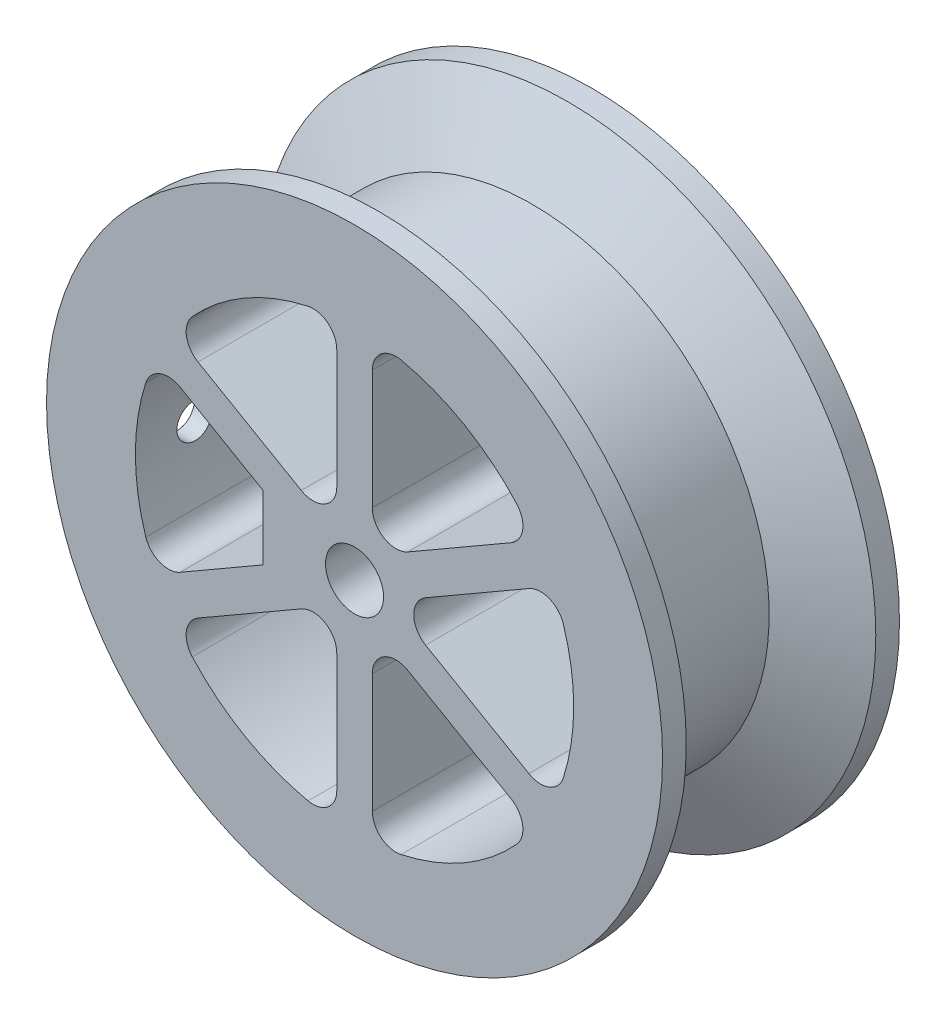
from build123d import *

# Parameters (mm, degrees)
SKETCH4_R                 = 3.1115
CUT_EXTRUDE1_DEPTH        = 26.4
CUT_EXTRUDE2_DEPTH        = 26.4
CIRPATTERN1_COUNT         = 6
SKETCH6_W                 = 5.08
SKETCH6_H                 = 6.929069256
BOSS_EXTRUDE2_DEPTH       = 25.4
F_4_CLEARANCE_HOLE1_D     = 3.4544
F_4_CLEARANCE_HOLE1_DEPTH = 12.7
F_4_CLEARANCE_HOLE1_TIP   = 1.037806461
SKETCH10_R                = 1.905
CUT_EXTRUDE3_DEPTH        = 24.20925
CUT_EXTRUDE7_START        = -1.778
CUT_EXTRUDE7_DEPTH        = 2.413


with BuildPart() as part:
    # Sketch2 → Revolve1 (revolve)
    with BuildSketch(Plane(origin=(0, 0, 0), x_dir=(1, 0, 0), z_dir=(0, 1, 0))):
        Polygon((0, 12.7), (33.02, 12.7), (33.02, 10.16), (25.4, 6.35), (25.4, -10.16), (33.02, -10.16), (33.02, -12.7), (0, -12.7), align=None)
    revolve(axis=Axis((0, 0, -12.7), (0, 0, 1)))

    # Sketch4 → Cut-Extrude1 (cut, through all)
    with BuildSketch(Plane.XY.offset(12.7)):
        Circle(SKETCH4_R)
    extrude(amount=-CUT_EXTRUDE1_DEPTH, mode=Mode.SUBTRACT)

    # Sketch5 → Cut-Extrude2 (cut, through all)
    with BuildSketch(Plane.XY.offset(12.7)):
        with BuildLine():
            Line((5.715, 5.499261314), (16.782084856, 11.888845735))
            ThreePointArc((16.782084856, 11.888845735), (18.021662818, 13.696608361), (17.392337565, 15.796253322))
            ThreePointArc((17.392337565, 15.796253322), (11.7475, 20.347266862), (4.983787879, 22.960332824))
            ThreePointArc((4.983787879, 22.960332824), (2.850779377, 22.455521999), (1.905, 20.478134681))
            Line((1.905, 20.478134681), (1.905, 7.69896584))
            ThreePointArc((1.905, 7.69896584), (3.175, 5.499261314), (5.715, 5.499261314))
        make_face()
    cut_extrude2 = extrude(amount=-CUT_EXTRUDE2_DEPTH, mode=Mode.SUBTRACT)

    # CirPattern1: Cut-Extrude2 ×6 about axis
    cirpattern1_axis = Axis((0, 0, 0), (0, 0, 1))
    for i in range(1, CIRPATTERN1_COUNT):
        add(cut_extrude2.rotate(cirpattern1_axis, i * 360 / CIRPATTERN1_COUNT), mode=Mode.SUBTRACT)

    # Sketch6 → Boss-Extrude2 (add, through all)
    with BuildSketch(Plane.XY.offset(12.7)):
        with Locations((-7.27075, 0)):
            Rectangle(SKETCH6_W, SKETCH6_H)
    extrude(amount=-BOSS_EXTRUDE2_DEPTH)

    # 4 Clearance Hole1
    with Locations(Plane.ZY.offset(9.81075)):
        with Locations((6.35, 0)):
            Hole(F_4_CLEARANCE_HOLE1_D / 2, depth=F_4_CLEARANCE_HOLE1_DEPTH)
            with Locations((0, 0, -(F_4_CLEARANCE_HOLE1_DEPTH + F_4_CLEARANCE_HOLE1_TIP / 2))):  # 118° drill point
                Cone(0, F_4_CLEARANCE_HOLE1_D / 2, F_4_CLEARANCE_HOLE1_TIP, mode=Mode.SUBTRACT)

    # Sketch10 → Cut-Extrude3 (cut, through all)
    with BuildSketch(Plane.ZY.offset(9.81075)):
        with Locations((6.35, 0)):
            Circle(SKETCH10_R)
    extrude(amount=CUT_EXTRUDE3_DEPTH, mode=Mode.SUBTRACT)

    # Sketch15 → Cut-Extrude7 (cut)
    with BuildSketch(Plane.ZY.offset(9.81075).offset(CUT_EXTRUDE7_START)):
        Polygon((-12.7, -3.429), (8.329734073, -3.429), (10.309468146, 0), (8.329734073, 3.429), (-12.7, 3.429), align=None)
    extrude(amount=-CUT_EXTRUDE7_DEPTH, mode=Mode.SUBTRACT)

    # Sketch16 → Cut-Revolve1 (revolve, cut)
    with BuildSketch(Plane(origin=(0, 0, 0), x_dir=(1, 0, 0), z_dir=(0, 1, 0))):
        Polygon((0, 5.08), (23.495, 12.7), (0, 12.7), align=None)
    revolve(axis=Axis((0, 0, 12.7), (0, 0, -1)), mode=Mode.SUBTRACT)


solid = part.part
